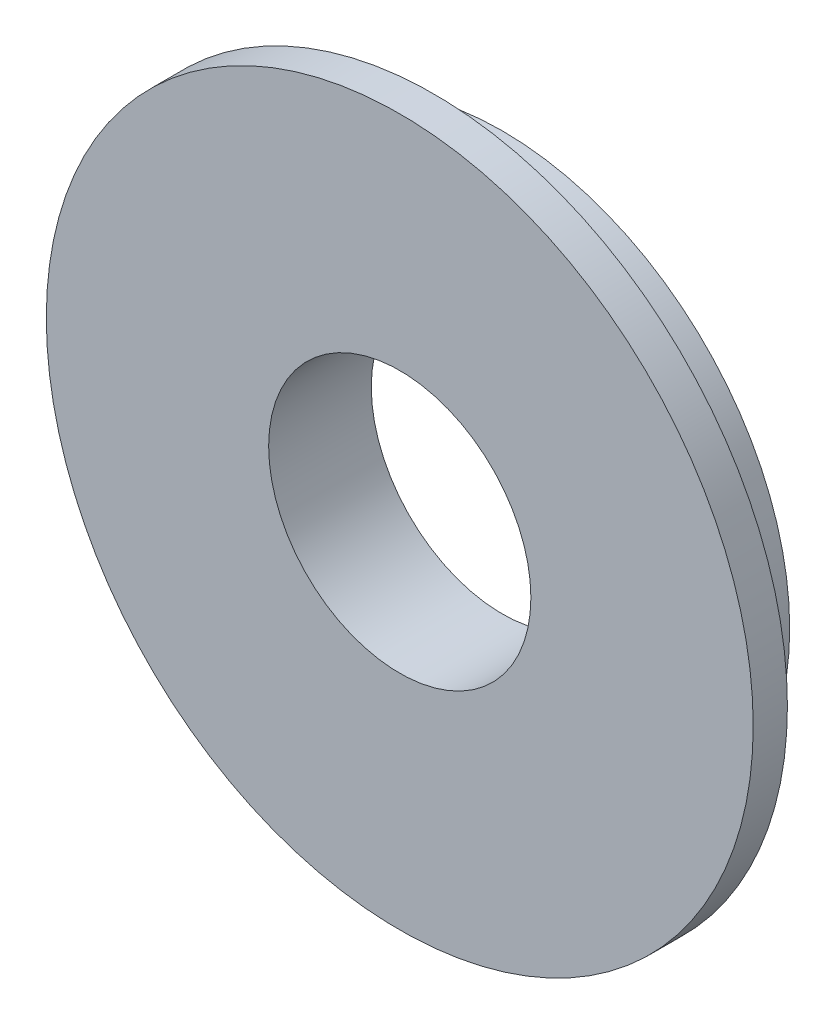
from build123d import *

# Parameters (mm, degrees)
SKETCH1_R           = 15.5
SKETCH1_R_2         = 5.75
BOSS_EXTRUDE1_DEPTH = 1.5
SKETCH2_R           = 12.6
SKETCH2_R_2         = 5.75
BOSS_EXTRUDE2_DEPTH = 3


with BuildPart() as part:
    # Sketch1 → Boss-Extrude1 (new body)
    with BuildSketch(Plane.XY):
        Circle(SKETCH1_R)
        Circle(SKETCH1_R_2, mode=Mode.SUBTRACT)
    extrude(amount=BOSS_EXTRUDE1_DEPTH)

    # Sketch2 → Boss-Extrude2 (add)
    with BuildSketch(Plane(origin=(0, 0, 0), x_dir=(-1, 0, 0), z_dir=(0, 0, -1))):
        Circle(SKETCH2_R)
        Circle(SKETCH2_R_2, mode=Mode.SUBTRACT)
    extrude(amount=BOSS_EXTRUDE2_DEPTH)


solid = part.part
